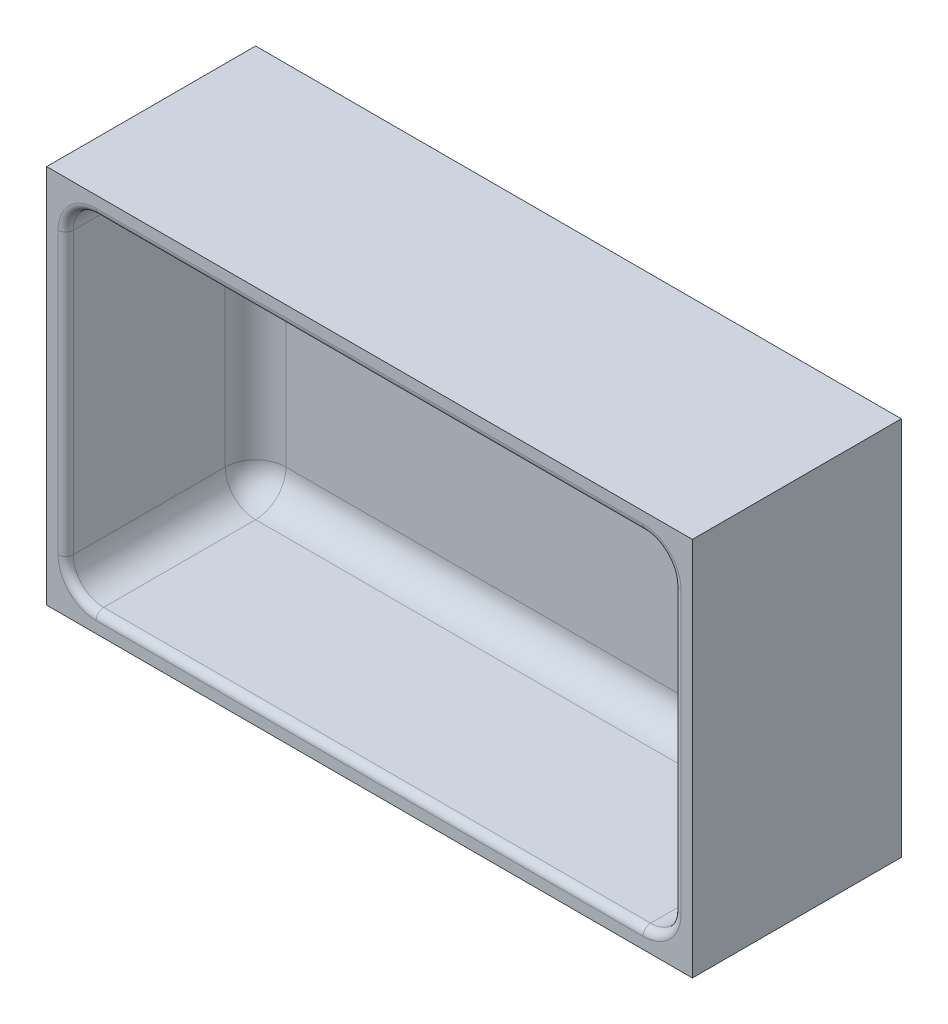
from build123d import *

# Parameters (mm, degrees)
IZIM1_W                     = 90
IZIM1_H                     = 160
Y_KSEKLIK_EKSTR_ZYON1_DEPTH = 5
IZIM1_3_W                   = 100
IZIM1_3_H                   = 170
IZIM1_3_W_2                 = 90
IZIM1_3_H_2                 = 160
Y_KSEKLIK_EKSTR_ZYON2_DEPTH = 55
RADYUS1_R                   = 8
RADYUS2_R                   = 2


with BuildPart() as part:
    # Çizim1 → Yükseklik-Ekstrüzyon1 (new body)
    with BuildSketch(Plane(origin=(0, 0, 0), x_dir=(0, 1, 0), z_dir=(0, 0, 1))):
        with Locations((50, 85)):
            Rectangle(IZIM1_W, IZIM1_H)
    extrude(amount=Y_KSEKLIK_EKSTR_ZYON1_DEPTH)

    # Çizim1<3> → Yükseklik-Ekstrüzyon2 (add)
    with BuildSketch(Plane(origin=(0, 0, 0), x_dir=(0, 1, 0), z_dir=(0, 0, 1))):
        with Locations((50, 85)):
            Rectangle(IZIM1_3_W, IZIM1_3_H)
        with Locations((50, 85)):
            Rectangle(IZIM1_3_W_2, IZIM1_3_H_2, mode=Mode.SUBTRACT)
    extrude(amount=Y_KSEKLIK_EKSTR_ZYON2_DEPTH)

    # Radyus1
    radyus1_edges = [part.edges().sort_by_distance(p)[0] for p in [
        (-5, 95, 30),
        (-5, 5, 30),
        (-165, 95, 30),
        (-165, 5, 30),
        (-165, 50, 5),
        (-5, 50, 5),
        (-85, 95, 5),
        (-85, 5, 5),
    ]]
    fillet(radyus1_edges, radius=RADYUS1_R)

    # Radyus2
    radyus2_edges = [part.edges().sort_by_distance(p)[0] for p in [
        (-162.656854249, 7.343145751, 55),
        (-165, 50, 55),
        (-162.656854249, 92.656854249, 55),
        (-85, 95, 55),
        (-7.343145751, 92.656854249, 55),
        (-5, 50, 55),
        (-7.343145751, 7.343145751, 55),
        (-85, 5, 55),
    ]]
    fillet(radyus2_edges, radius=RADYUS2_R)


solid = part.part
